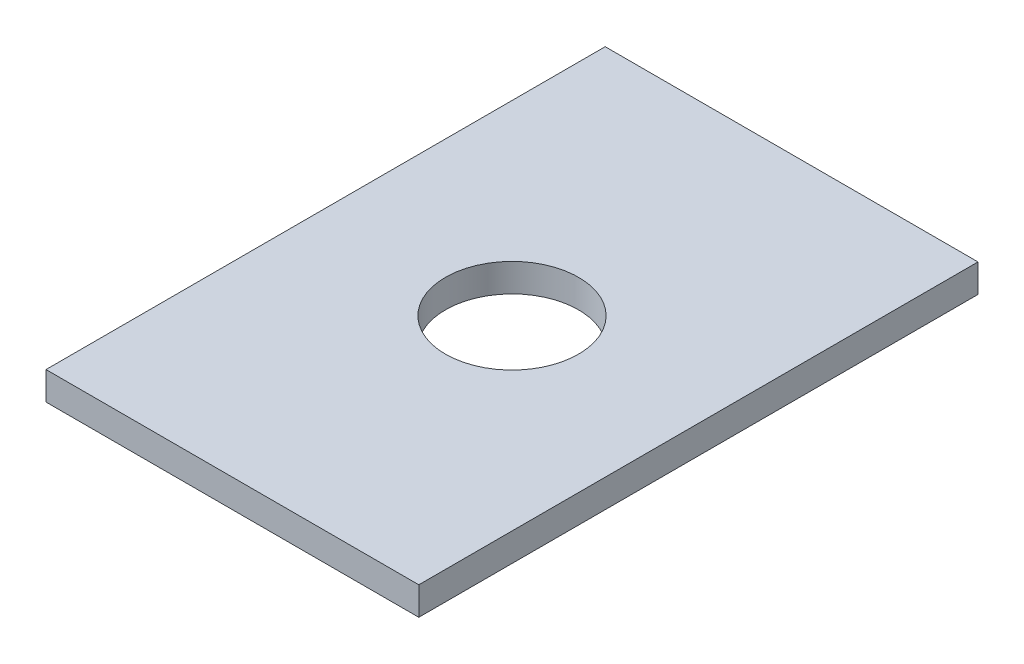
from build123d import *

# Parameters (mm, degrees)
SKETCH1_W           = 42
SKETCH1_H           = 63
SKETCH1_R           = 7.5
BOSS_EXTRUDE1_DEPTH = 3.175


with BuildPart() as part:
    # Sketch1 → Boss-Extrude1 (new body)
    with BuildSketch(Plane(origin=(0, 0, 0), x_dir=(1, 0, 0), z_dir=(0, 1, 0))):
        Rectangle(SKETCH1_W, SKETCH1_H)
        Circle(SKETCH1_R, mode=Mode.SUBTRACT)
    extrude(amount=BOSS_EXTRUDE1_DEPTH)


solid = part.part
